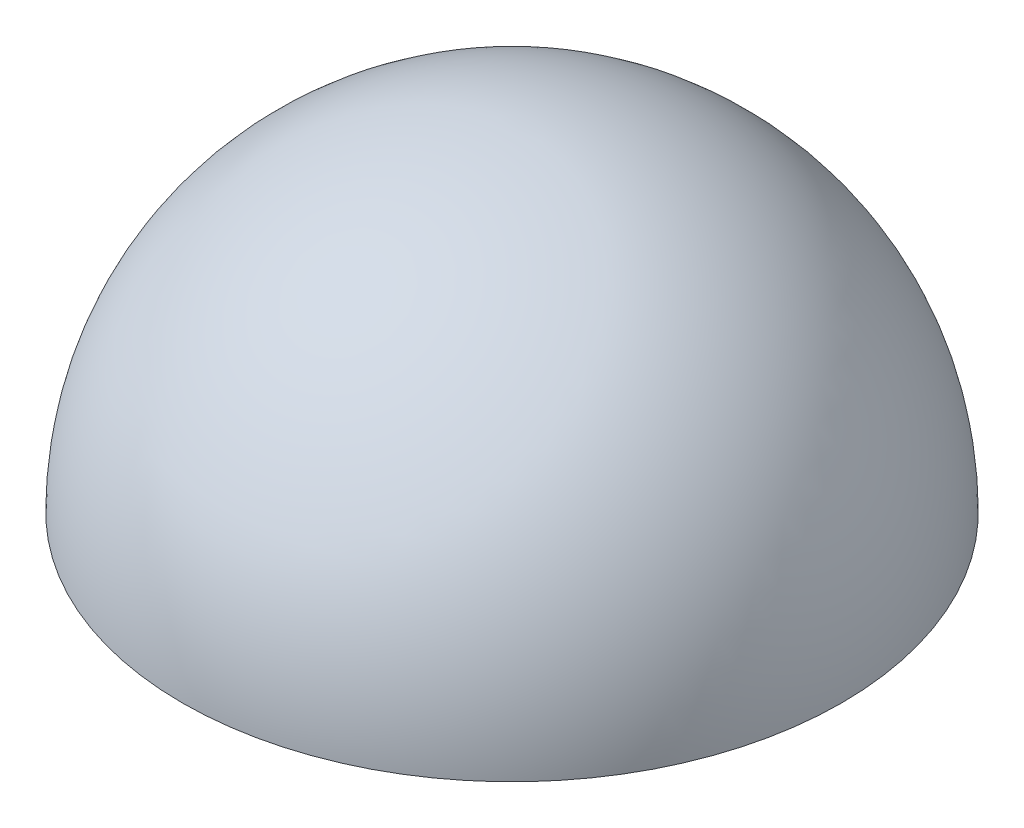
from build123d import *


with BuildPart() as part:
    # 草图1 → 旋转1 (revolve)
    with BuildSketch(Plane.XY):
        with BuildLine():
            Line((-70, 0), (0, 0))
            Line((0, 0), (0, 70))
            ThreePointArc((0, 70), (-49.497474683, 49.497474683), (-70, 0))
        make_face()
    revolve(axis=Axis((0, -70, 0), (0, 1, 0)))


solid = part.part
